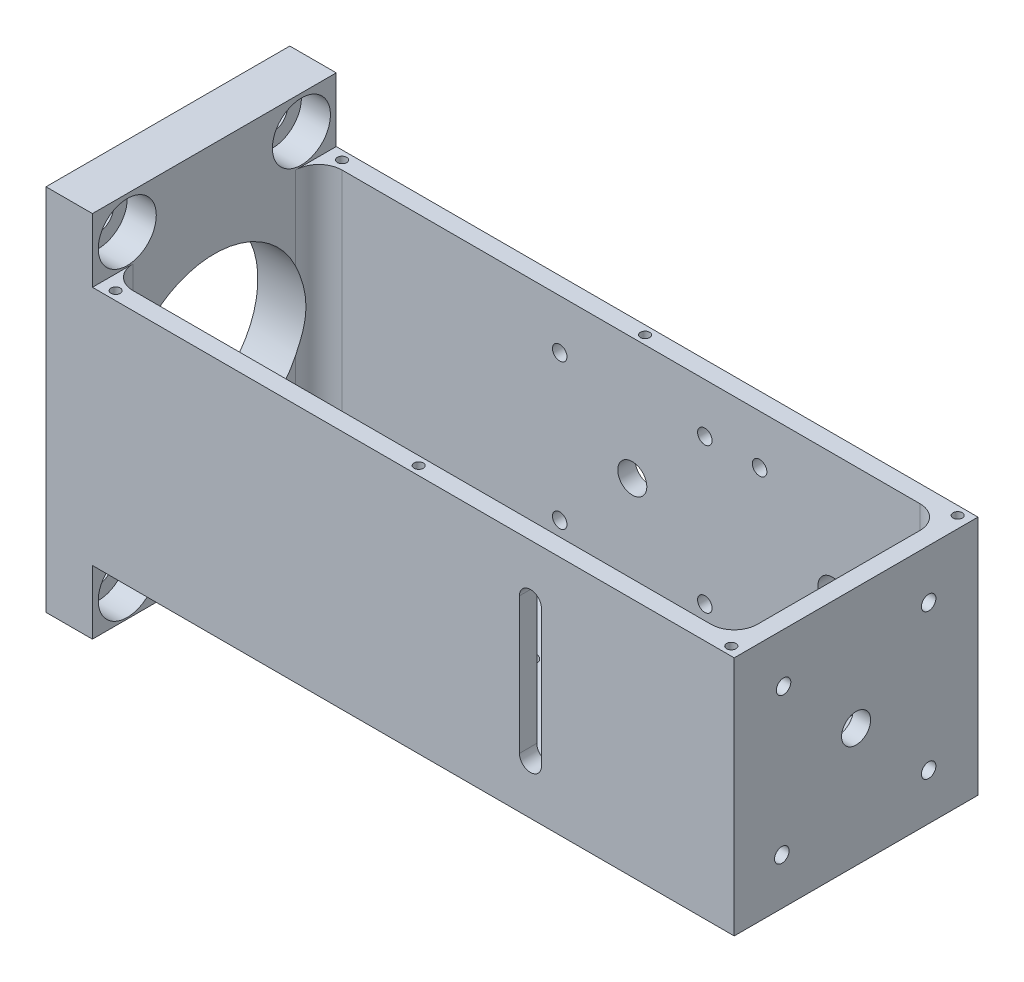
from build123d import *

# Parameters (mm, degrees)
SKETCH1_W                        = 118.56
SKETCH1_H                        = 42
BOSS_EXTRUDE1_DEPTH              = 41.5
SKETCH2_W                        = 107.56
SKETCH2_H                        = 36
CUT_EXTRUDE1_DEPTH               = 37.5
FILLET1_R                        = 4
CUT_EXTRUDE2_REACH               = 120.56
SKETCH3_R                        = 15.5
CUT_EXTRUDE5_REACH               = 44
SKETCH22_W                       = 8
SKETCH22_H                       = 42
BOSS_EXTRUDE3_DEPTH              = 11
SKETCH23_W                       = 8
SKETCH23_H                       = 42
BOSS_EXTRUDE4_DEPTH              = 11
F_4_0MM_DOWEL_HOLE2_D            = 4
F_4_0MM_DOWEL_HOLE2_DEPTH        = 4.5
F_4_0MM_DOWEL_HOLE2_TIP          = 1.201721238
CBORE_FOR_M5_SHCS1_D             = 5.3
CBORE_FOR_M5_SHCS1_CBORE_D       = 10
CBORE_FOR_M5_SHCS1_CBORE_DEPTH   = 5
F_5_0MM_DOWEL_HOLE1_D            = 5
F_5_0MM_DOWEL_HOLE1_DEPTH        = 3
F_5_0MM_DOWEL_HOLE2_D            = 5
F_5_0MM_DOWEL_HOLE2_DEPTH        = 3
M3X0_5_TAPPED_HOLE1_D            = 2.5
M3X0_5_TAPPED_HOLE1_DEPTH        = 3
M3X0_5_TAPPED_HOLE2_D            = 2.5
M3X0_5_TAPPED_HOLE2_DEPTH        = 3
F_3_0MM_DOWEL_HOLE1_D            = 3
F_3_0MM_DOWEL_HOLE1_DEPTH        = 3
F_3_0MM_DOWEL_HOLE1_TIP          = 0.901290929
CBORE_FOR_M2_5_SHCS1_D           = 2.9
CBORE_FOR_M2_5_SHCS1_DEPTH       = 4
CBORE_FOR_M2_5_SHCS1_CBORE_D     = 5.5
CBORE_FOR_M2_5_SHCS1_CBORE_DEPTH = 2.5
F_1_16_0_0625_DOWEL_HOLE1_D      = 1.5875
F_1_16_0_0625_DOWEL_HOLE1_DEPTH  = 3
F_1_16_0_0625_DOWEL_HOLE1_TIP    = 0.476933116
CBORE_FOR_M2_SHCS1_D             = 2.2
CBORE_FOR_M2_SHCS1_DEPTH         = 4
CBORE_FOR_M2_SHCS1_CBORE_D       = 4.4
CBORE_FOR_M2_SHCS1_CBORE_DEPTH   = 2
F_3_0MM_DOWEL_HOLE2_D            = 3
F_3_0MM_DOWEL_HOLE2_DEPTH        = 3
F_3_0MM_DOWEL_HOLE2_TIP          = 0.901290929
CBORE_FOR_M2_5_SHCS2_D           = 2.9
CBORE_FOR_M2_5_SHCS2_DEPTH       = 4
CBORE_FOR_M2_5_SHCS2_CBORE_D     = 5.5
CBORE_FOR_M2_5_SHCS2_CBORE_DEPTH = 2.5
M2X0_4_TAPPED_HOLE1_D            = 1.6
M2X0_4_TAPPED_HOLE1_DEPTH        = 5.2
M2X0_4_TAPPED_HOLE1_TIP          = 0.480688495


with BuildPart() as part:
    # Sketch1 → Boss-Extrude1 (new body)
    with BuildSketch(Plane(origin=(0, 0, 0), x_dir=(1, 0, 0), z_dir=(0, 1, 0))):
        Rectangle(SKETCH1_W, SKETCH1_H)
    extrude(amount=BOSS_EXTRUDE1_DEPTH)

    # Sketch2 → Cut-Extrude1 (cut)
    with BuildSketch(Plane(origin=(0, 41.5, 0), x_dir=(1, 0, 0), z_dir=(0, 1, 0))):
        with Locations((2.5, 0)):
            Rectangle(SKETCH2_W, SKETCH2_H)
    extrude(amount=-CUT_EXTRUDE1_DEPTH, mode=Mode.SUBTRACT)

    # Fillet1
    fillet1_edges = [part.edges().sort_by_distance(p)[0] for p in [
        (-51.28, 22.75, 18),
        (-51.28, 22.75, -18),
        (56.28, 22.75, -18),
        (56.28, 22.75, 18),
    ]]
    fillet(fillet1_edges, radius=FILLET1_R)

    # Sketch3 → Cut-Extrude2 (cut, up to next)
    with BuildSketch(Plane.ZY.offset(59.28), mode=Mode.PRIVATE) as cut_extrude2_sk1:
        with Locations((0, 20.5)):
            Circle(SKETCH3_R)
    cut_extrude2_tool1 = extrude(cut_extrude2_sk1.sketch, amount=-CUT_EXTRUDE2_REACH, mode=Mode.PRIVATE) & part.part
    add(cut_extrude2_tool1.solids().sort_by_distance((-59.28, 20.5, 0))[0], mode=Mode.SUBTRACT)

    # Sketch10 → Cut-Extrude5 (cut, up to next)
    with BuildSketch(Plane.XY.offset(21), mode=Mode.PRIVATE) as cut_extrude5_sk1:
        with BuildLine():
            Line((26.08, 32.25), (26.08, 8.75))
            ThreePointArc((26.08, 8.75), (24.18, 6.85), (22.28, 8.75))
            Line((22.28, 8.75), (22.28, 32.25))
            ThreePointArc((22.28, 32.25), (24.18, 34.15), (26.08, 32.25))
        make_face()
    cut_extrude5_tool1 = extrude(cut_extrude5_sk1.sketch, amount=-CUT_EXTRUDE5_REACH, mode=Mode.PRIVATE) & part.part
    add(cut_extrude5_tool1.solids().sort_by_distance((24.18, 20.5, 21))[0], mode=Mode.SUBTRACT)

    # Sketch22 → Boss-Extrude3 (add)
    with BuildSketch(Plane.XZ):
        with Locations((-55.28, 0)):
            Rectangle(SKETCH22_W, SKETCH22_H)
    extrude(amount=BOSS_EXTRUDE3_DEPTH)

    # Sketch23 → Boss-Extrude4 (add)
    with BuildSketch(Plane(origin=(0, 41.5, 0), x_dir=(1, 0, 0), z_dir=(0, 1, 0))):
        with Locations((-55.28, 0)):
            Rectangle(SKETCH23_W, SKETCH23_H)
    extrude(amount=BOSS_EXTRUDE4_DEPTH)

    # Ø4.0mm Dowel Hole2
    with Locations(Plane.ZY.offset(59.28)):
        with Locations((0, 46.75), (0, -5.75)):
            Hole(F_4_0MM_DOWEL_HOLE2_D / 2, depth=F_4_0MM_DOWEL_HOLE2_DEPTH)
            with Locations((0, 0, -(F_4_0MM_DOWEL_HOLE2_DEPTH + F_4_0MM_DOWEL_HOLE2_TIP / 2))):  # 118° drill point
                Cone(0, F_4_0MM_DOWEL_HOLE2_D / 2, F_4_0MM_DOWEL_HOLE2_TIP, mode=Mode.SUBTRACT)

    # CBORE for M5 SHCS1 (through all)
    with Locations(Plane(origin=(-51.28, 0, 0), x_dir=(0, 0, -1), z_dir=(1, 0, 0))):
        with Locations((-15, 46.75), (15, 46.75), (-15, -5.75), (15, -5.75)):
            CounterBoreHole(CBORE_FOR_M5_SHCS1_D / 2, CBORE_FOR_M5_SHCS1_CBORE_D / 2, CBORE_FOR_M5_SHCS1_CBORE_DEPTH)

    # Ø5.0mm Dowel Hole1
    with Locations(Plane(origin=(0, 0, -21), x_dir=(-1, 0, 0), z_dir=(0, 0, -1))):
        with Locations((-2.721503605, 20.5), (-37.207540509, 20.5)):
            Hole(F_5_0MM_DOWEL_HOLE1_D / 2, depth=F_5_0MM_DOWEL_HOLE1_DEPTH)

    # Ø5.0mm Dowel Hole2
    with Locations(Plane(origin=(59.28, 0, 0), x_dir=(0, 0, -1), z_dir=(1, 0, 0))):
        with Locations((0, 20.5)):
            Hole(F_5_0MM_DOWEL_HOLE2_D / 2, depth=F_5_0MM_DOWEL_HOLE2_DEPTH)

    # M3x0.5 Tapped Hole1
    with Locations(Plane(origin=(0, 0, -21), x_dir=(-1, 0, 0), z_dir=(0, 0, -1))):
        with Locations((9.778496395, 8), (-15.221503605, 8), (-15.221503605, 33), (9.778496395, 33), (-24.656395143, 7.948854634), (-49.758685875, 7.948854634), (-49.758685875, 33.051145366), (-24.656395143, 33.051145366)):
            Hole(M3X0_5_TAPPED_HOLE1_D / 2, depth=M3X0_5_TAPPED_HOLE1_DEPTH)

    # M3x0.5 Tapped Hole2
    with Locations(Plane(origin=(59.28, 0, 0), x_dir=(0, 0, -1), z_dir=(1, 0, 0))):
        with Locations((12.5, 8), (-12.798632739, 8), (-12.5, 33), (12.5, 33)):
            Hole(M3X0_5_TAPPED_HOLE2_D / 2, depth=M3X0_5_TAPPED_HOLE2_DEPTH)

    # Ø3.0mm Dowel Hole1
    with Locations(Plane(origin=(0, 4, 0), x_dir=(1, 0, 0), z_dir=(0, 1, 0))):
        with Locations((-4.703117598, -10.253048327), (12.974551932, 7.424621202)):
            Hole(F_3_0MM_DOWEL_HOLE1_D / 2, depth=F_3_0MM_DOWEL_HOLE1_DEPTH)
            with Locations((0, 0, -(F_3_0MM_DOWEL_HOLE1_DEPTH + F_3_0MM_DOWEL_HOLE1_TIP / 2))):  # 118° drill point
                Cone(0, F_3_0MM_DOWEL_HOLE1_D / 2, F_3_0MM_DOWEL_HOLE1_TIP, mode=Mode.SUBTRACT)

    # CBORE for M2.5 SHCS1
    with Locations(Plane(origin=(0, 0, 0), x_dir=(-1, 0, 0), z_dir=(0, -1, 0))):
        with Locations((-4.170075035, -1.448571431)):
            CounterBoreHole(CBORE_FOR_M2_5_SHCS1_D / 2, CBORE_FOR_M2_5_SHCS1_CBORE_D / 2, CBORE_FOR_M2_5_SHCS1_CBORE_DEPTH, depth=CBORE_FOR_M2_5_SHCS1_DEPTH)

    # 1/16 (0.0625) Dowel Hole1
    with Locations(Plane(origin=(0, 4, 0), x_dir=(1, 0, 0), z_dir=(0, 1, 0))):
        with Locations((41.086220165, -3.878679656), (33.328860853, 3.878679656)):
            Hole(F_1_16_0_0625_DOWEL_HOLE1_D / 2, depth=F_1_16_0_0625_DOWEL_HOLE1_DEPTH)
            with Locations((0, 0, -(F_1_16_0_0625_DOWEL_HOLE1_DEPTH + F_1_16_0_0625_DOWEL_HOLE1_TIP / 2))):  # 118° drill point
                Cone(0, F_1_16_0_0625_DOWEL_HOLE1_D / 2, F_1_16_0_0625_DOWEL_HOLE1_TIP, mode=Mode.SUBTRACT)

    # CBORE for M2 SHCS1
    with Locations(Plane(origin=(0, 0, 0), x_dir=(-1, 0, 0), z_dir=(0, -1, 0))):
        with Locations((-41.086220165, 3.878679656), (-33.328860853, -3.878679656)):
            CounterBoreHole(CBORE_FOR_M2_SHCS1_D / 2, CBORE_FOR_M2_SHCS1_CBORE_D / 2, CBORE_FOR_M2_SHCS1_CBORE_DEPTH, depth=CBORE_FOR_M2_SHCS1_DEPTH)

    # Ø3.0mm Dowel Hole2
    with Locations(Plane(origin=(0, 4, 0), x_dir=(1, 0, 0), z_dir=(0, 1, 0))):
        with Locations((23.894423104, -11.836644244), (23.126634177, 10.14995395)):
            Hole(F_3_0MM_DOWEL_HOLE2_D / 2, depth=F_3_0MM_DOWEL_HOLE2_DEPTH)
            with Locations((0, 0, -(F_3_0MM_DOWEL_HOLE2_DEPTH + F_3_0MM_DOWEL_HOLE2_TIP / 2))):  # 118° drill point
                Cone(0, F_3_0MM_DOWEL_HOLE2_D / 2, F_3_0MM_DOWEL_HOLE2_TIP, mode=Mode.SUBTRACT)

    # CBORE for M2.5 SHCS2
    with Locations(Plane(origin=(0, 0, 0), x_dir=(-1, 0, 0), z_dir=(0, -1, 0))):
        with Locations((-23.458179395, 0.655741094)):
            CounterBoreHole(CBORE_FOR_M2_5_SHCS2_D / 2, CBORE_FOR_M2_5_SHCS2_CBORE_D / 2, CBORE_FOR_M2_5_SHCS2_CBORE_DEPTH, depth=CBORE_FOR_M2_5_SHCS2_DEPTH)

    # M2x0.4 Tapped Hole1
    with Locations(Plane(origin=(0, 41.5, 0), x_dir=(1, 0, 0), z_dir=(0, 1, 0))):
        with Locations((57.28, -19.5), (3.420478131, -19.5), (-48.78, -19.5), (-48.78, 19.5), (3.420478131, 19.5), (57.28, 19.5)):
            Hole(M2X0_4_TAPPED_HOLE1_D / 2, depth=M2X0_4_TAPPED_HOLE1_DEPTH)
            with Locations((0, 0, -(M2X0_4_TAPPED_HOLE1_DEPTH + M2X0_4_TAPPED_HOLE1_TIP / 2))):  # 118° drill point
                Cone(0, M2X0_4_TAPPED_HOLE1_D / 2, M2X0_4_TAPPED_HOLE1_TIP, mode=Mode.SUBTRACT)


solid = part.part
